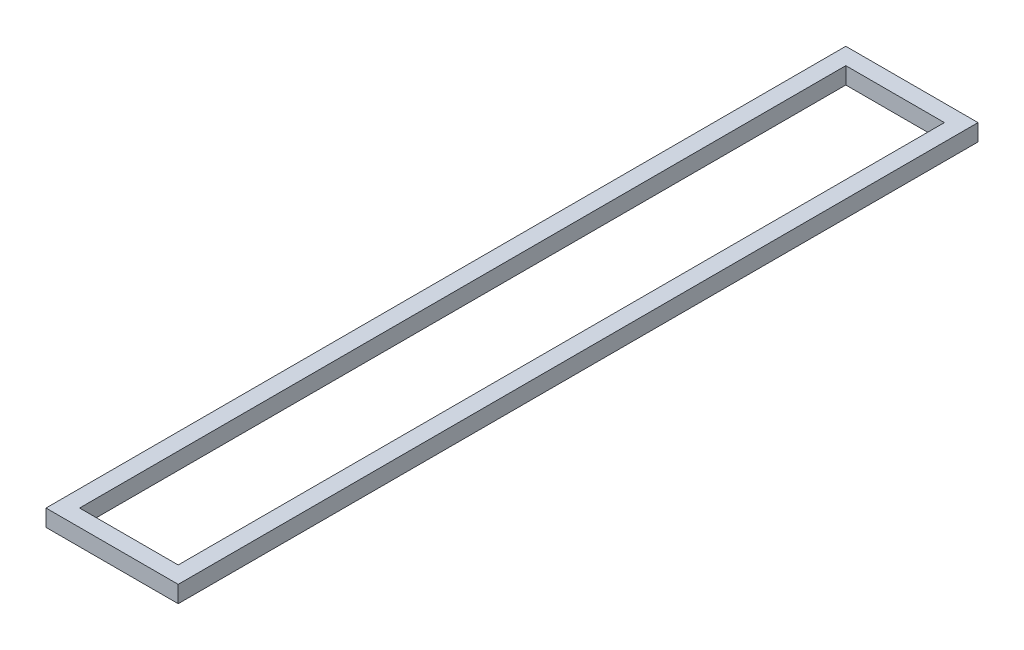
from build123d import *

# Parameters (mm, degrees)
SKETCH2_W   = 25.4
SKETCH2_H   = 25.4
SKETCH2_W_2 = 23
SKETCH2_H_2 = 23


with BuildPart() as part:
    # Sweep1: sweep along a path in Sketch1
    with BuildLine(Plane(origin=(0, 0, 0), x_dir=(1, 0, 0), z_dir=(0, 1, 0))) as sweep1_path:
        Line((-100, 605), (100, 605))
        Line((100, 605), (100, -605))
        Line((100, -605), (-100, -605))
        Line((-100, -605), (-100, 605))
    # Sketch2 → Sweep1 (sweep)
    with BuildSketch(Plane(origin=(0, 0, 0), x_dir=(0, 0, -1), z_dir=(1, 0, 0))):
        with Locations((-592.3, 12.7)):
            Rectangle(SKETCH2_W, SKETCH2_H)
        with Locations((-592.3, 12.7)):
            Rectangle(SKETCH2_W_2, SKETCH2_H_2, mode=Mode.SUBTRACT)
    sweep(path=sweep1_path.line, transition=Transition.RIGHT)


solid = part.part
